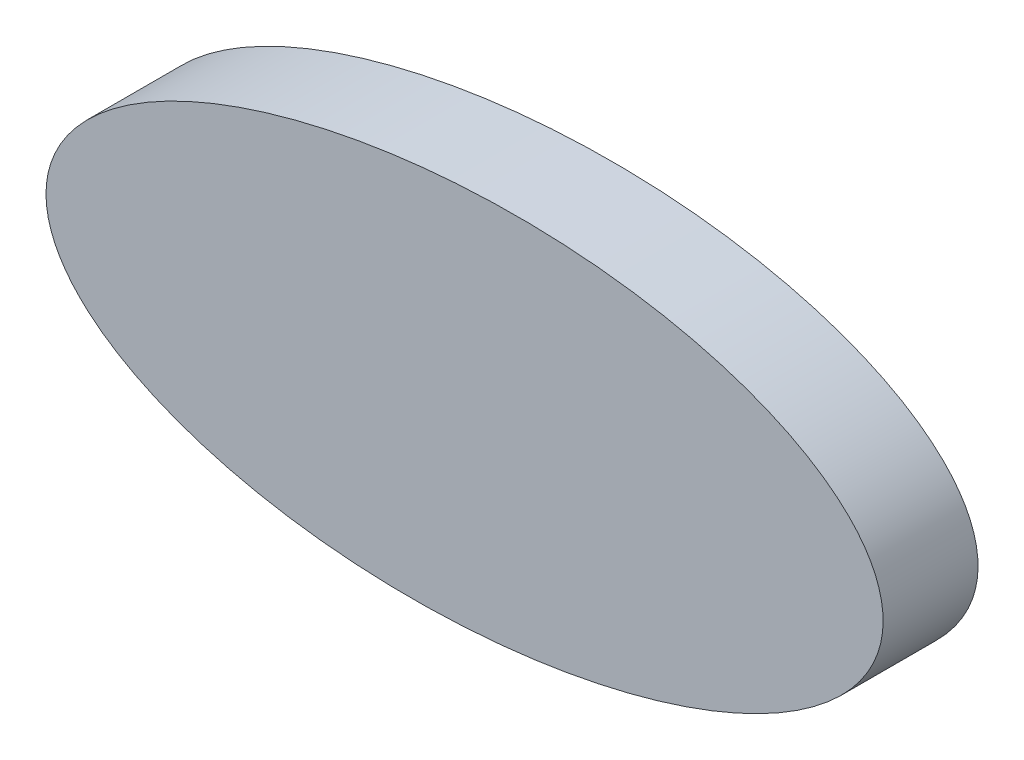
from build123d import *

# Parameters (mm, degrees)
SKETCH1_RX          = 44.195778581
SKETCH1_RY          = 20.005573444
BOSS_EXTRUDE1_DEPTH = 10


with BuildPart() as part:
    # Sketch1 → Boss-Extrude1 (new body)
    with BuildSketch(Plane.XY):
        with Locations(Location((0, 0), (0, 0, 4.197668357))):
            Ellipse(SKETCH1_RX, SKETCH1_RY)
    extrude(amount=BOSS_EXTRUDE1_DEPTH)


solid = part.part
